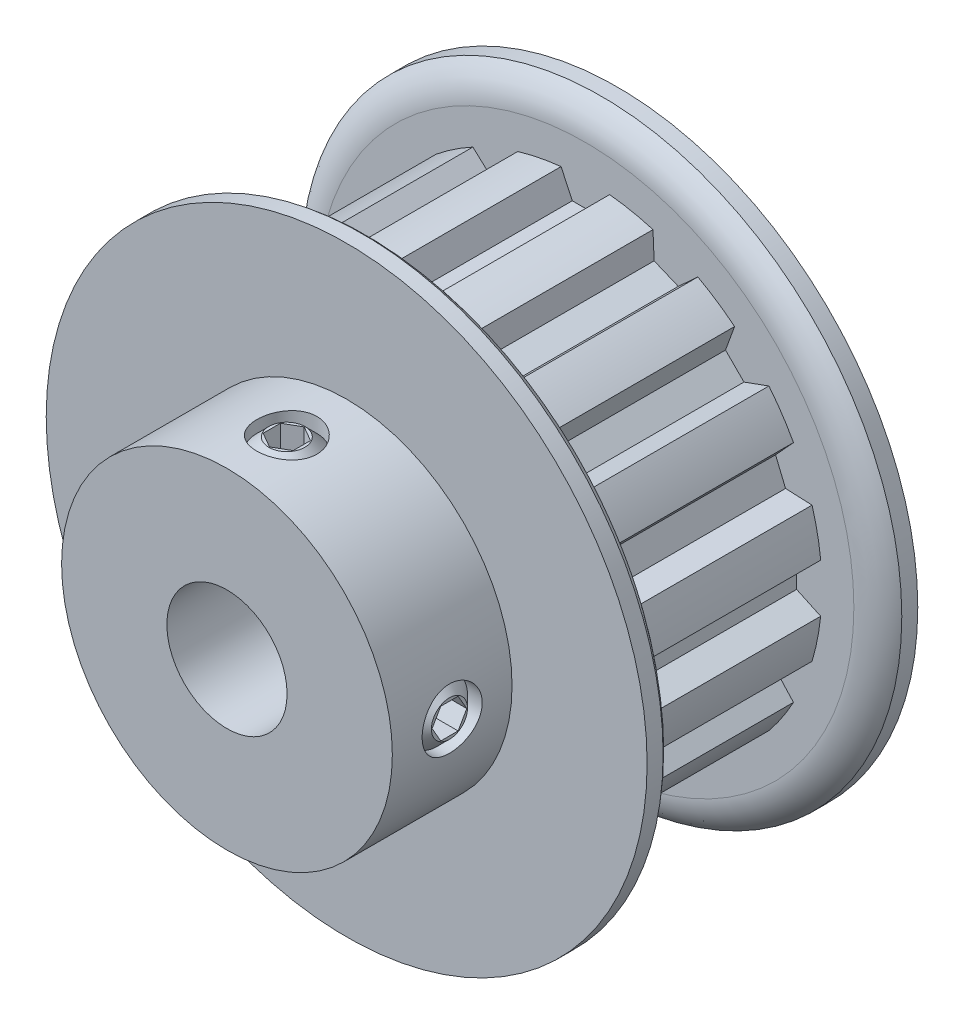
from build123d import *

# Parameters (mm, degrees)
CUT_EXTRUDE1_START = 2.2987
CUT_EXTRUDE1_DEPTH = 10.922
CIRPATTERN1_COUNT  = 16
SKETCH4_R          = 1.5875
CUT_EXTRUDE2_DEPTH = 25.705805871
CUT_EXTRUDE3_DEPTH = 1.190625
CIRPATTERN2_COUNT  = 2
CIRPATTERN2_ANGLE  = 90


with BuildPart() as part:
    # Sketch2 → Revolve1 (revolve)
    with BuildSketch(Plane(origin=(0, 0, 0), x_dir=(0, 0, -1), z_dir=(1, 0, 0)), mode=Mode.PRIVATE) as revolve1_sk:
        with BuildLine():
            Line((-10.3124, 3.175), (10.3124, 3.175))
            Line((10.3124, 3.175), (10.3124, 15.875))
            Line((10.3124, 15.875), (9.46785, 15.875))
            ThreePointArc((9.46785, 15.875), (8.846219323, 15.130824061), (8.6233, 14.187145354))
            Line((8.6233, 14.187145354), (8.6233, 12.499290707))
            Line((8.6233, 12.499290707), (-2.2987, 12.499290707))
            Line((-2.2987, 12.499290707), (-2.2987, 14.187145354))
            ThreePointArc((-2.2987, 14.187145354), (-2.521619323, 15.130824061), (-3.14325, 15.875))
            Line((-3.14325, 15.875), (-3.9878, 15.875))
            Line((-3.9878, 15.875), (-3.9878, 8.7376))
            Line((-3.9878, 8.7376), (-10.3124, 8.7376))
            Line((-10.3124, 8.7376), (-10.3124, 3.175))
        make_face()
    revolve(revolve1_sk.sketch.rotate(Axis((0, 0, 10.3124), (0, 0, -1)), 90), axis=Axis((0, 0, 10.3124), (0, 0, -1)))

    # Sketch3 → Cut-Extrude1 (cut)
    with BuildSketch(Plane.XY.offset(CUT_EXTRUDE1_START)):
        with BuildLine():
            Line((-0.690489274, 11.1633), (0.690489274, 11.1633))
            Line((0.690489274, 11.1633), (1.2827, 12.4333))
            ThreePointArc((1.2827, 12.4333), (0, 12.499290707), (-1.2827, 12.4333))
            Line((-1.2827, 12.4333), (-0.690489274, 11.1633))
        make_face()
    cut_extrude1 = extrude(amount=-CUT_EXTRUDE1_DEPTH, mode=Mode.SUBTRACT)

    # CirPattern1: Cut-Extrude1 ×16 about axis
    cirpattern1_axis = Axis((0, 0, 0), (0, 0, 1))
    for i in range(1, CIRPATTERN1_COUNT):
        add(cut_extrude1.rotate(cirpattern1_axis, i * 360 / CIRPATTERN1_COUNT), mode=Mode.SUBTRACT)

    # Sketch4 → Cut-Extrude2 (cut, through all)
    with BuildSketch(Plane(origin=(0, 0, 0), x_dir=(1, 0, 0), z_dir=(0, 1, 0))):
        with Locations(Location((0, -7.1501, 0), (0, 0, 90))):
            Circle(SKETCH4_R)
    cut_extrude2 = extrude(amount=CUT_EXTRUDE2_DEPTH, mode=Mode.SUBTRACT)

    # Sketch5 → Revolve2 (revolve)
    with BuildSketch(Plane.XY.offset(7.1501), mode=Mode.PRIVATE) as revolve2_sk:
        Polygon((0, 8.592176529), (0, 3.175), (-0.9525, 3.175), (-1.5875, 3.81), (-1.5875, 7.957176529), (-0.9525, 8.592176529), align=None)
    revolve2 = revolve(revolve2_sk.sketch.rotate(Axis((0, 0, 7.1501), (0, 1, 0)), 270), axis=Axis((0, 0, 7.1501), (0, 1, 0)))

    # Sketch6 → Cut-Extrude3 (cut)
    with BuildSketch(Plane(origin=(0, 8.592176529, 0), x_dir=(-1, 0, 0), z_dir=(0, -1, 0))):
        Polygon((0, -6.233556448), (-0.79375, -6.691828224), (-0.79375, -7.608371776), (0, -8.066643552), (0.79375, -7.608371776), (0.79375, -6.691828224), align=None)
    cut_extrude3 = extrude(amount=CUT_EXTRUDE3_DEPTH, mode=Mode.SUBTRACT)

    # CirPattern2: Cut-Extrude2, Revolve2, Cut-Extrude3 ×2 about axis
    cirpattern2_axis = Axis((0, 0, 0), (0, 0, -1))
    add([cut_extrude2.rotate(cirpattern2_axis, i * CIRPATTERN2_ANGLE / (CIRPATTERN2_COUNT - 1)) for i in range(1, CIRPATTERN2_COUNT)], mode=Mode.SUBTRACT)
    add([revolve2.rotate(cirpattern2_axis, i * CIRPATTERN2_ANGLE / (CIRPATTERN2_COUNT - 1)) for i in range(1, CIRPATTERN2_COUNT)])
    add([cut_extrude3.rotate(cirpattern2_axis, i * CIRPATTERN2_ANGLE / (CIRPATTERN2_COUNT - 1)) for i in range(1, CIRPATTERN2_COUNT)], mode=Mode.SUBTRACT)


solid = part.part
